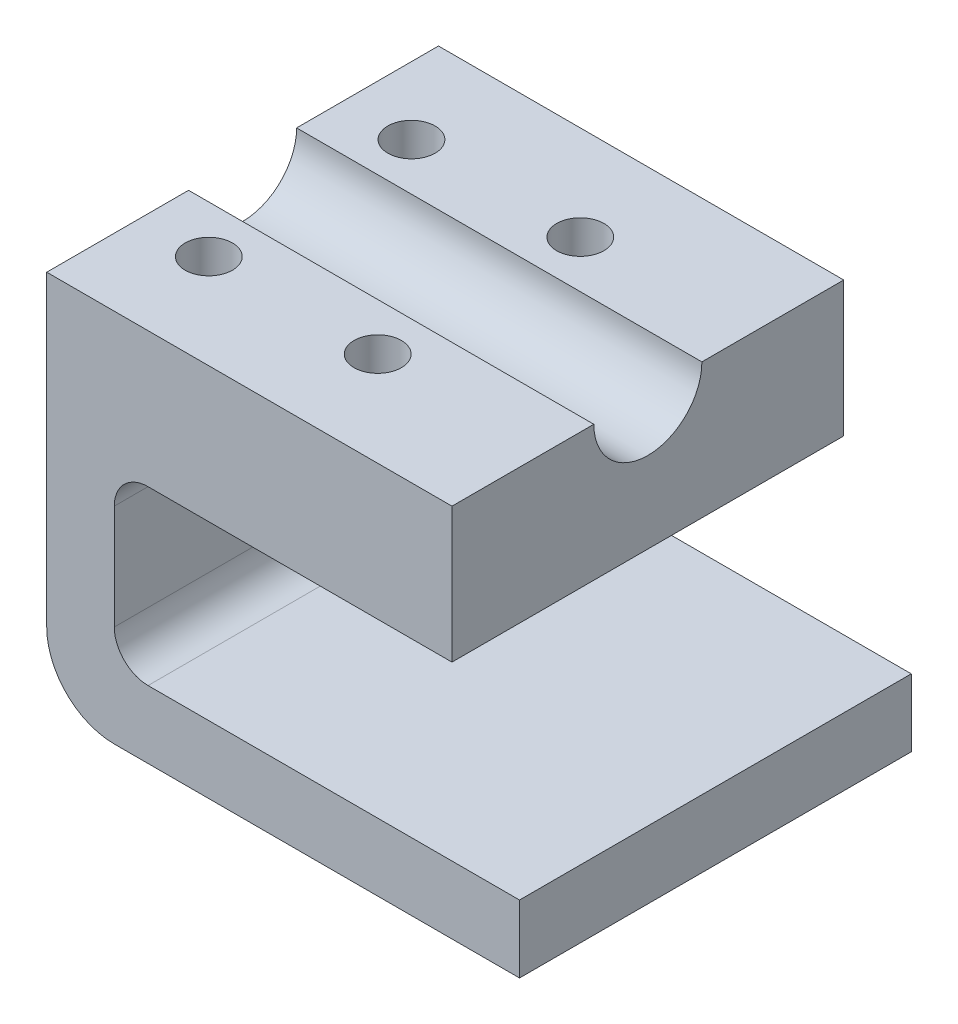
from build123d import *

# Parameters (mm, degrees)
BOSS_EXTRUDE1_DEPTH = 58
SKETCH2_R           = 8
CUT_EXTRUDE1_DEPTH  = 60
SKETCH3_R           = 3.5
CUT_EXTRUDE2_DEPTH  = 18
FILLET1_R           = 5


with BuildPart() as part:
    # Sketch1 → Boss-Extrude1 (new body)
    with BuildSketch(Plane.XY):
        with BuildLine():
            Line((0, 0), (0, 25.5))
            Line((0, 25.5), (50, 25.5))
            Line((50, 25.5), (50, 45.5))
            Line((50, 45.5), (-10, 45.5))
            Line((-10, 45.5), (-10, 0))
            ThreePointArc((-10, 0), (-7.071067812, -7.071067812), (0, -10))
            Line((0, -10), (60, -10))
            Line((60, -10), (60, 0))
            Line((60, 0), (0, 0))
        make_face()
    extrude(amount=BOSS_EXTRUDE1_DEPTH)

    # Sketch2 → Cut-Extrude1 (cut)
    with BuildSketch(Plane.ZY.offset(10)):
        with Locations((29, 45.5)):
            Circle(SKETCH2_R)
    extrude(amount=-CUT_EXTRUDE1_DEPTH, mode=Mode.SUBTRACT)

    # Sketch3 → Cut-Extrude2 (cut)
    with BuildSketch(Plane(origin=(0, 45.5, 0), x_dir=(1, 0, 0), z_dir=(0, 1, 0))):
        with Locations((0, -14)):
            Circle(SKETCH3_R)
        with Locations((0, -44)):
            Circle(SKETCH3_R)
        with Locations((25, -14)):
            Circle(SKETCH3_R)
        with Locations((25, -44)):
            Circle(SKETCH3_R)
    extrude(amount=-CUT_EXTRUDE2_DEPTH, mode=Mode.SUBTRACT)

    # Fillet1
    fillet1_edges = [part.edges().sort_by_distance(p)[0] for p in [
        (0, 25.5, 29),
        (0, 0, 29),
    ]]
    fillet(fillet1_edges, radius=FILLET1_R)


solid = part.part
